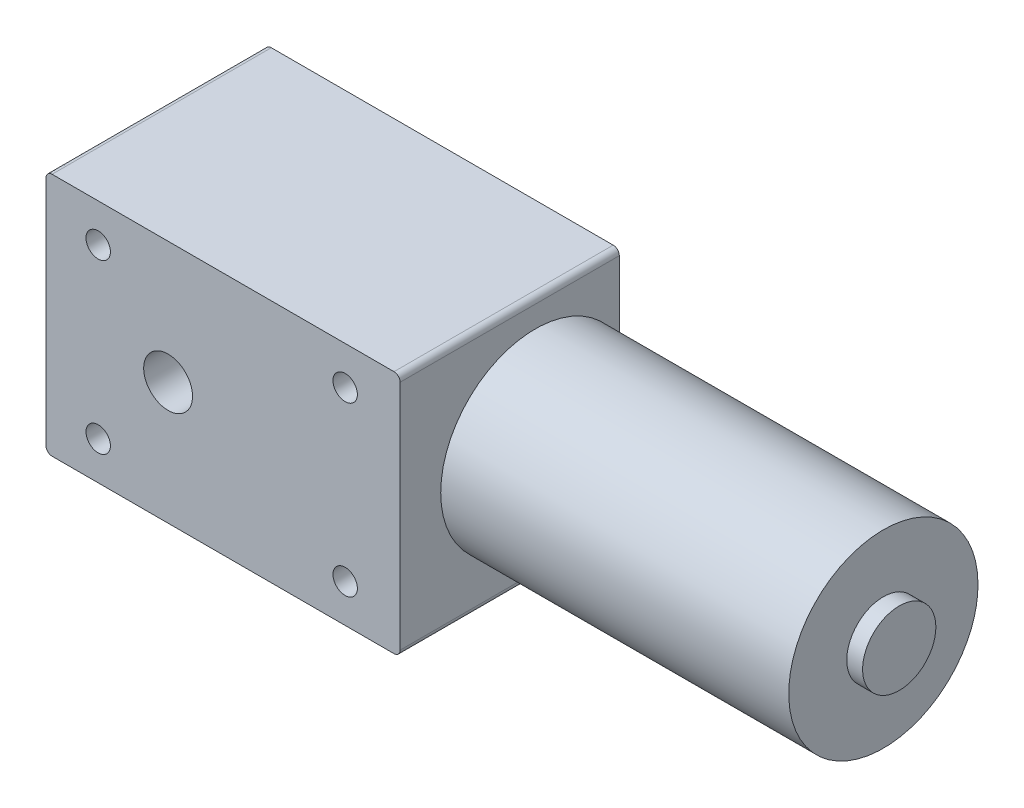
from build123d import *

# Parameters (mm, degrees)
SKETCH1_R                = 15.5
BOSS_EXTRUDE1_DEPTH      = 57
SKETCH2_R                = 6
BOSS_EXTRUDE2_DEPTH      = 2.6
SKETCH3_W                = 58
SKETCH3_H                = 40
SKETCH3_R                = 2
SKETCH3_R_2              = 4
BOSS_EXTRUDE3_DEPTH      = 22.15
BOSS_EXTRUDE3_DEPTH_BACK = 13.75
FILLET1_R                = 1


with BuildPart() as part:
    # Sketch1 → Boss-Extrude1 (new body)
    with BuildSketch(Plane(origin=(0, 0, 0), x_dir=(0, 0, -1), z_dir=(1, 0, 0))):
        Circle(SKETCH1_R)
    extrude(amount=BOSS_EXTRUDE1_DEPTH)

    # Sketch2 → Boss-Extrude2 (add)
    with BuildSketch(Plane(origin=(57, 0, 0), x_dir=(0, 0, -1), z_dir=(1, 0, 0))):
        Circle(SKETCH2_R)
    extrude(amount=BOSS_EXTRUDE2_DEPTH)

    # Sketch3 → Boss-Extrude3 (add, two sides)
    with BuildSketch(Plane.XY) as boss_extrude3_sk:
        with Locations((-29, 0)):
            Rectangle(SKETCH3_W, SKETCH3_H)
        with Locations((-9, 13.75)):
            Circle(SKETCH3_R, mode=Mode.SUBTRACT)
        with Locations((-49.45, 13.75)):
            Circle(SKETCH3_R, mode=Mode.SUBTRACT)
        with Locations((-49.45, -13.75)):
            Circle(SKETCH3_R, mode=Mode.SUBTRACT)
        with Locations((-9, -13.75)):
            Circle(SKETCH3_R, mode=Mode.SUBTRACT)
        with Locations((-38, 0)):
            Circle(SKETCH3_R_2, mode=Mode.SUBTRACT)
    extrude(amount=BOSS_EXTRUDE3_DEPTH)
    extrude(boss_extrude3_sk.sketch, amount=-BOSS_EXTRUDE3_DEPTH_BACK)

    # Fillet1
    fillet1_edges = [part.edges().sort_by_distance(p)[0] for p in [
        (0, 20, 4.2),
        (0, -20, 4.2),
        (-58, -20, 4.2),
        (-58, 20, 4.2),
    ]]
    fillet(fillet1_edges, radius=FILLET1_R)


solid = part.part
